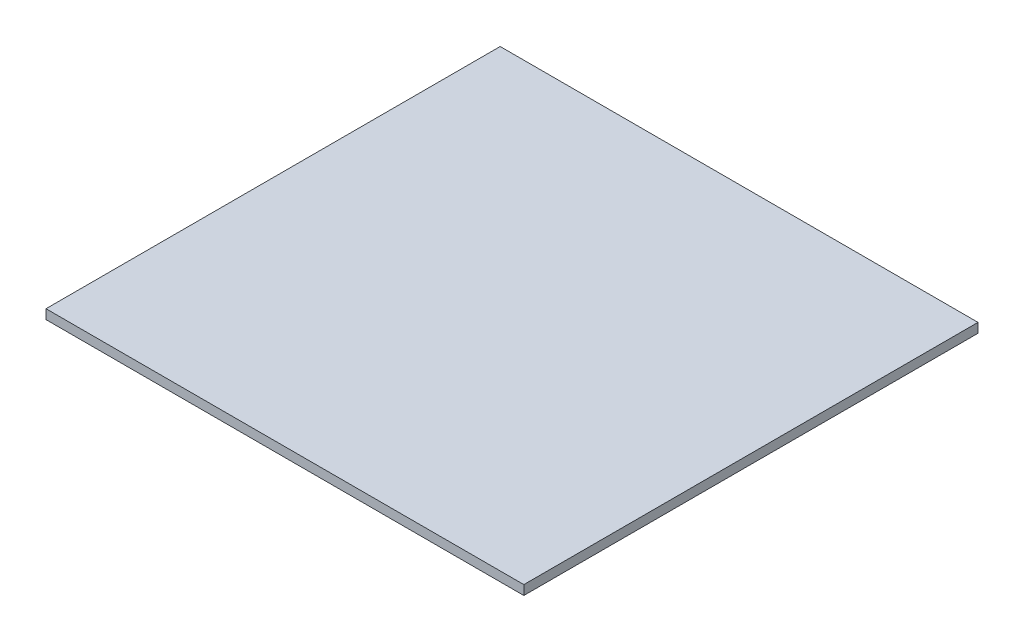
from build123d import *

# Parameters (mm, degrees)
CROQUIS1_W              = 505
CROQUIS1_H              = 480
SALIENTE_EXTRUIR1_DEPTH = 10


with BuildPart() as part:
    # Croquis1 → Saliente-Extruir1 (new body)
    with BuildSketch(Plane(origin=(0, 0, 0), x_dir=(1, 0, 0), z_dir=(0, 1, 0))):
        with Locations((12.814691152, -67.66875)):
            Rectangle(CROQUIS1_W, CROQUIS1_H)
    extrude(amount=SALIENTE_EXTRUIR1_DEPTH)


solid = part.part
